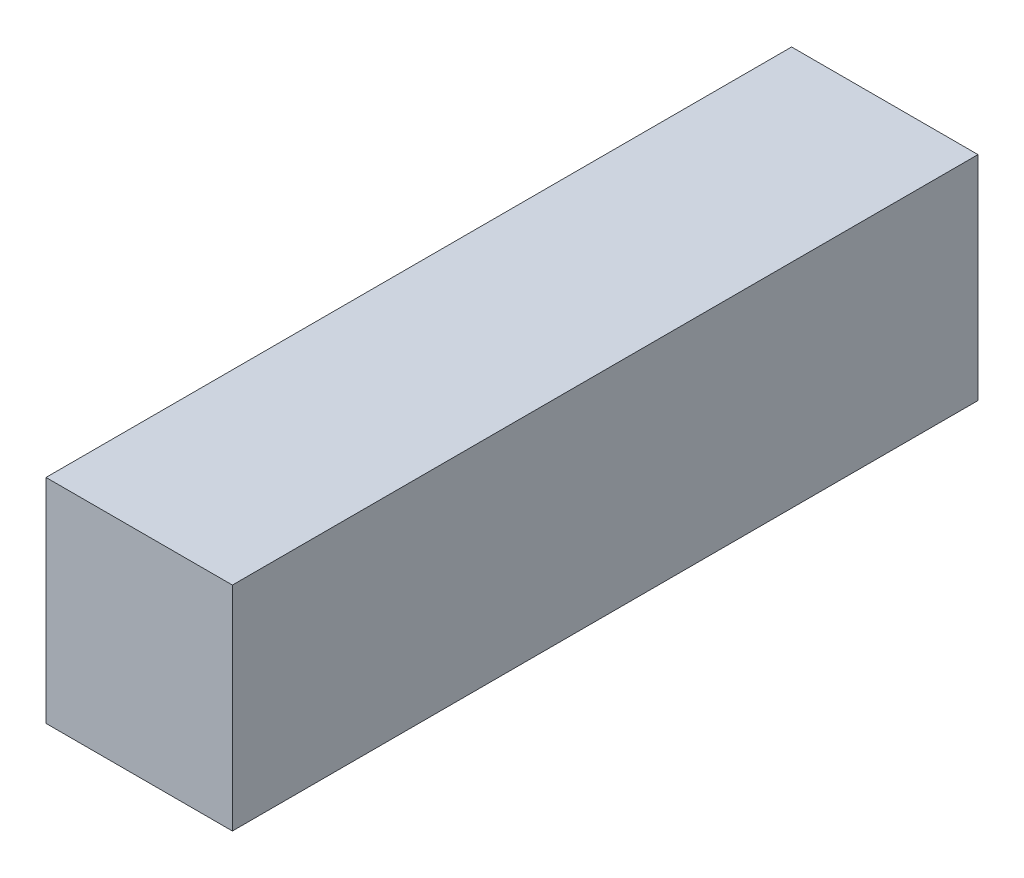
from build123d import *

# Parameters (mm, degrees)
SKETCH1_W           = 35
SKETCH1_H           = 140
BOSS_EXTRUDE1_DEPTH = 40


with BuildPart() as part:
    # Sketch1 → Boss-Extrude1 (new body)
    with BuildSketch(Plane(origin=(0, 0, 0), x_dir=(1, 0, 0), z_dir=(0, 1, 0))):
        Rectangle(SKETCH1_W, SKETCH1_H)
    extrude(amount=BOSS_EXTRUDE1_DEPTH)


solid = part.part
